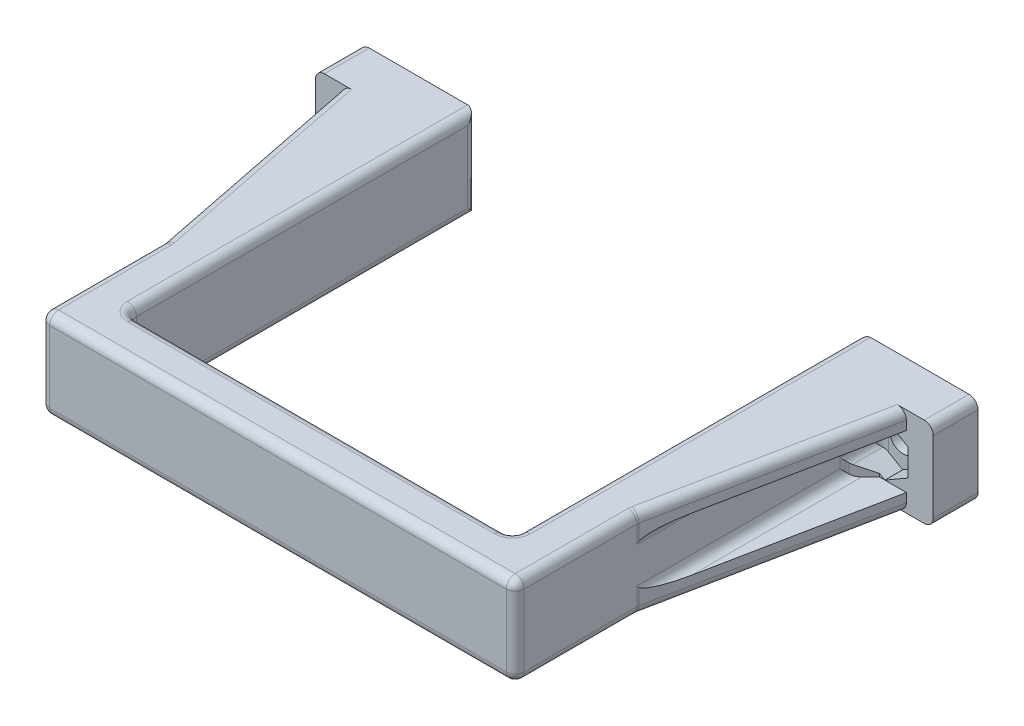
from build123d import *

# Parameters (mm, degrees)
BOSS_EXTRUDE1_DEPTH     = 5
CUT_EXTRUDE1_DEPTH      = 2
M2_5_CLEARANCE_HOLE1_D  = 2.9
RIB1_REACH              = 45.305
SKETCH5_WALL_W          = 114.10480654
SKETCH5_WALL_H          = 2
MIRROR2_COPY_1_REACH    = 45.305
MIRROR2_COPY_1_SKETCH_W = 114.10480654
MIRROR2_COPY_1_SKETCH_H = 2
CHAMFER1_SIZE           = 2
FILLET1_R               = 1


with BuildPart() as part:
    # Sketch1 → Boss-Extrude1 (new, symmetric)
    with BuildSketch(Plane(origin=(0, 0, 0), x_dir=(1, 0, 0), z_dir=(0, 1, 0))):
        Polygon((21.5, -19.5), (-21.5, -19.5), (-21.5, 19.5), (-34.5, 19.5), (-34.5, 14.5), (-26.5, 14.5), (-26.5, -24.188022284), (26.5, -24.188022284), (26.5, 14.5), (34.5, 14.5), (34.5, 19.5), (21.5, 19.5), align=None)
    extrude(amount=BOSS_EXTRUDE1_DEPTH, both=True)

    # Sketch2 → Cut-Extrude1 (cut)
    with BuildSketch(Plane.XY.offset(-14.5)):
        Polygon((-26.5, 1.5011107), (-29.1, 3.0022214), (-31.7, 1.5011107), (-31.7, -1.5011107), (-29.1, -3.0022214), (-26.5, -1.5011107), align=None)
    cut_extrude1 = extrude(amount=-CUT_EXTRUDE1_DEPTH, mode=Mode.SUBTRACT)

    # M2.5 Clearance Hole1 (through all)
    with Locations(Plane.XY.offset(-16.5)):
        with Locations((-29.1, 0)):
            m2_5_clearance_hole1 = Hole(M2_5_CLEARANCE_HOLE1_D / 2)

    # Sketch5 wall → Rib1 (add, up to next)
    with BuildSketch(Plane(origin=(-29, 5, -2), x_dir=(0.196116135138, 0, 0.980580675691), z_dir=(0.980580675691, 0, -0.196116135138)), mode=Mode.PRIVATE) as rib1_sk1:
        with Locations((0, 1)):
            Rectangle(SKETCH5_WALL_W, SKETCH5_WALL_H)
    rib1_tool1 = extrude(rib1_sk1.sketch, amount=RIB1_REACH, mode=Mode.PRIVATE) - part.part
    rib1 = rib1_tool1.solids().sort_by_distance((-29, 5, -2))[0]
    add(rib1)

    # Mirror1: Rib1 across plane
    add(rib1.mirror(Plane.ZX))

    # Mirror2: Cut-Extrude1, M2.5 Clearance Hole1, Rib1 across plane
    add(cut_extrude1.mirror(Plane(origin=(0, 0, 0), x_dir=(0, 0, 1), z_dir=(1, 0, 0))), mode=Mode.SUBTRACT)
    add(m2_5_clearance_hole1.mirror(Plane(origin=(0, 0, 0), x_dir=(0, 0, 1), z_dir=(1, 0, 0))), mode=Mode.SUBTRACT)
    add(rib1.mirror(Plane(origin=(0, 0, 0), x_dir=(0, 0, 1), z_dir=(1, 0, 0))))

    # Mirror2 copy 1 sketch → Mirror2 copy 1 (add, up to next)
    with BuildSketch(Plane(origin=(29, -5, -2), x_dir=(-0.196116135138, 0, 0.980580675691), z_dir=(-0.980580675691, 0, -0.196116135138)), mode=Mode.PRIVATE) as mirror2_copy_1_sk1:
        with Locations((0, 1)):
            Rectangle(MIRROR2_COPY_1_SKETCH_W, MIRROR2_COPY_1_SKETCH_H)
    mirror2_copy_1_tool1 = extrude(mirror2_copy_1_sk1.sketch, amount=MIRROR2_COPY_1_REACH, mode=Mode.PRIVATE) - part.part
    add(mirror2_copy_1_tool1.solids().sort_by_distance((29, -5, -2))[0])

    # Chamfer1
    chamfer1_edges = [part.edges().sort_by_distance(p)[0] for p in [
        (26.5, -2.25055535, -14.5),
        (26.5, 2.25055535, -14.5),
        (-26.5, -2.25055535, -14.5),
        (-26.5, 2.25055535, -14.5),
    ]]
    chamfer(chamfer1_edges, length=CHAMFER1_SIZE)

    # Fillet1
    fillet1_edges = [part.edges().sort_by_distance(p)[0] for p in [
        (-26.5, -5, 17.344011142),
        (-29, -5, -2),
        (-26.5, -3, -1),
        (-26.5, -4, 10.5),
        (0, -5, 24.188022284),
        (26.5, -1.5011107, -14.5),
        (26.5, 1.5011107, -14.5),
        (-34.5, -5, -17),
        (26.5, 0, -16.5),
        (34.5, 5, -17),
        (-21.5, -5, 0),
        (0, -5, 19.5),
        (21.5, -5, 0),
        (26.5, 5, 17.344011142),
        (34.5, -5, -17),
        (29, 5, -2),
        (26.5, 4, 10.5),
        (26.5, -5, 17.344011142),
        (26.5, -4, 10.5),
        (29, -5, -2),
        (26.5, 0, 24.188022284),
        (-26.5, 0, 24.188022284),
        (26.5, -3, -1),
        (-21.5, 0, -19.5),
        (-21.5, 0, 19.5),
        (21.5, 0, 19.5),
        (21.5, 0, -19.5),
        (21.5, 5, 0),
        (26.5, 3, -1),
        (26.5, 2.25055535, -12.5),
        (26.5, -2.25055535, -12.5),
        (-26.5, 3, -1),
        (-26.5, 2.25055535, -12.5),
        (-26.5, -2.25055535, -12.5),
        (0, 5, 19.5),
        (-21.5, 5, 0),
        (-26.5, 0, -16.5),
        (-26.5, 1.5011107, -14.5),
        (-26.5, -1.5011107, -14.5),
        (-34.5, 5, -17),
        (0, 5, 24.188022284),
        (-26.5, 5, 17.344011142),
        (-29, 5, -2),
        (-26.5, 4, 10.5),
    ]]
    fillet(fillet1_edges, radius=FILLET1_R)


solid = part.part
